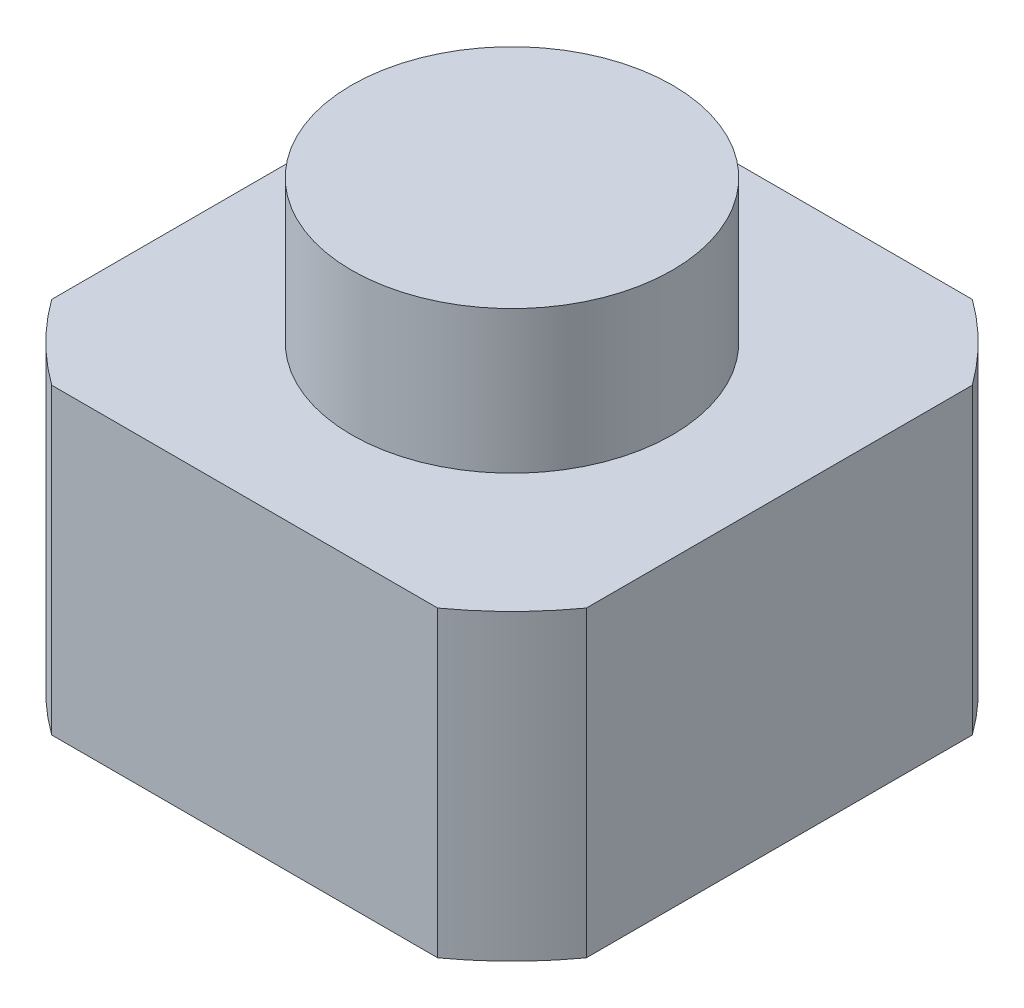
from build123d import *

# Parameters (mm, degrees)
BOSS_EXTRUDE1_DEPTH = 3.4
SKETCH3_R           = 1.8
BOSS_EXTRUDE2_DEPTH = 1.6


with BuildPart() as part:
    # Sketch2 → Boss-Extrude1 (new body)
    with BuildSketch(Plane(origin=(0, 0, 0), x_dir=(1, 0, 0), z_dir=(0, 1, 0))):
        with BuildLine():
            Line((-2.165640783, -3), (2.165640783, -3))
            ThreePointArc((2.165640783, -3), (2.61629509, -2.61629509), (3, -2.165640783))
            Line((3, -2.165640783), (3, 2.165640783))
            ThreePointArc((3, 2.165640783), (2.61629509, 2.61629509), (2.165640783, 3))
            Line((2.165640783, 3), (-2.165640783, 3))
            ThreePointArc((-2.165640783, 3), (-2.61629509, 2.61629509), (-3, 2.165640783))
            Line((-3, 2.165640783), (-3, -2.165640783))
            ThreePointArc((-3, -2.165640783), (-2.61629509, -2.61629509), (-2.165640783, -3))
        make_face()
    extrude(amount=BOSS_EXTRUDE1_DEPTH)

    # Sketch3 → Boss-Extrude2 (add)
    with BuildSketch(Plane(origin=(0, 3.4, 0), x_dir=(1, 0, 0), z_dir=(0, 1, 0))):
        with Locations(Location((0, 0, 0), (0, 0, 270))):  # turned: the seam where the file's is
            Circle(SKETCH3_R)
    extrude(amount=BOSS_EXTRUDE2_DEPTH)


solid = part.part
